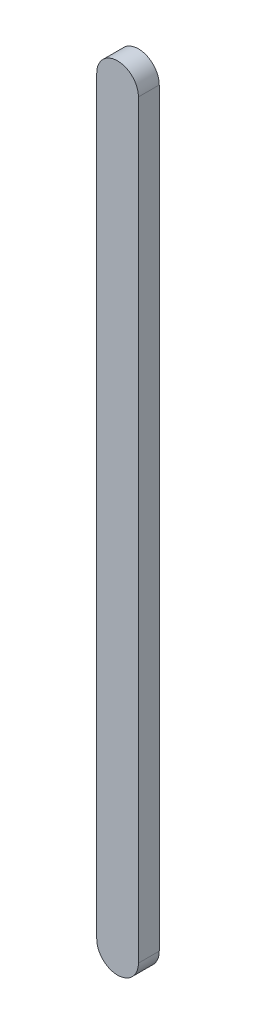
from build123d import *

# Parameters (mm, degrees)
EXTRUDE_1_DEPTH = 5


with BuildPart() as part:
    # 草图1 → 凸台-拉伸1 (new body)
    with BuildSketch(Plane.XY):
        with BuildLine():
            Line((5, 0), (5, -180))
            ThreePointArc((5, -180), (0, -185), (-5, -180))
            Line((-5, -180), (-5, 0))
            ThreePointArc((-5, 0), (0, 5), (5, 0))
        make_face()
    extrude(amount=EXTRUDE_1_DEPTH)


solid = part.part
